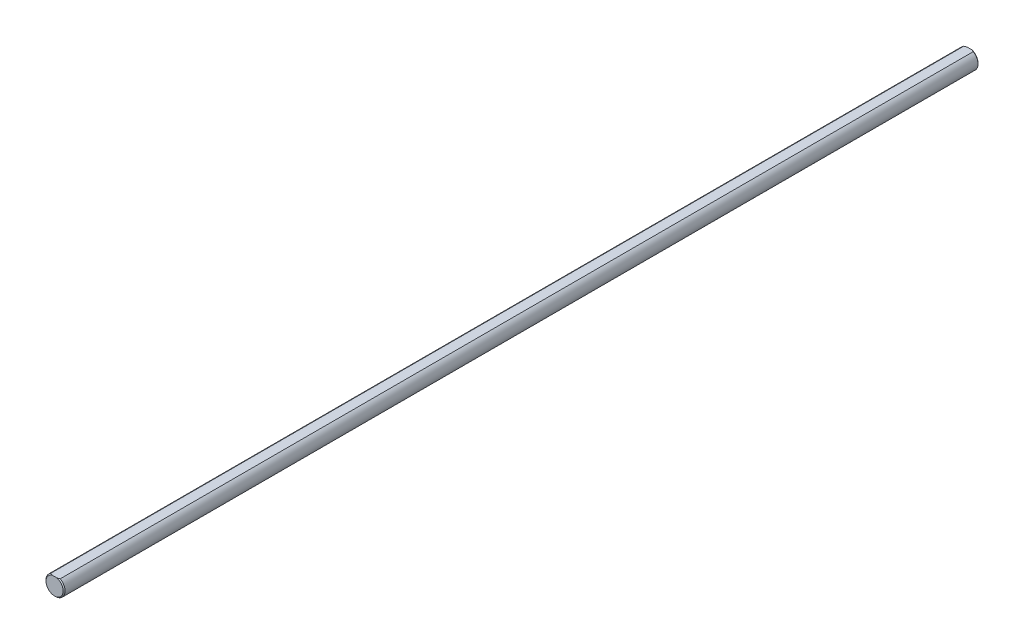
from build123d import *

# Parameters (mm, degrees)
SKETCH3_R                = 3.175
BOSS_EXTRUDE2_DEPTH      = 152.4
BOSS_EXTRUDE2_DEPTH_BACK = 152.4
CUT_EXTRUDE5_DEPTH       = 153.4
CUT_EXTRUDE5_DEPTH_BACK  = 153.4
CHAMFER1_SIZE            = 0.3175


with BuildPart() as part:
    # Sketch3 → Boss-Extrude2 (new body, two sides)
    with BuildSketch(Plane.XY) as boss_extrude2_sk:
        Circle(SKETCH3_R)
    extrude(amount=BOSS_EXTRUDE2_DEPTH)
    extrude(boss_extrude2_sk.sketch, amount=-BOSS_EXTRUDE2_DEPTH_BACK)

    # Sketch10 → Cut-Extrude5 (cut, two sides)
    with BuildSketch(Plane.XY) as cut_extrude5_sk:
        with BuildLine():
            Line((-1.5875, 2.749630657), (1.5875, 2.749630657))
            ThreePointArc((1.5875, 2.749630657), (0, 3.175), (-1.5875, 2.749630657))
        make_face()
    extrude(amount=CUT_EXTRUDE5_DEPTH, mode=Mode.SUBTRACT)
    extrude(cut_extrude5_sk.sketch, amount=-CUT_EXTRUDE5_DEPTH_BACK, mode=Mode.SUBTRACT)

    # Chamfer1
    chamfer1_edges = [part.edges().sort_by_distance(p)[0] for p in [
        (0, -3.175, -152.4),
        (0, -3.175, 152.4),
    ]]
    chamfer(chamfer1_edges, length=CHAMFER1_SIZE)


solid = part.part
